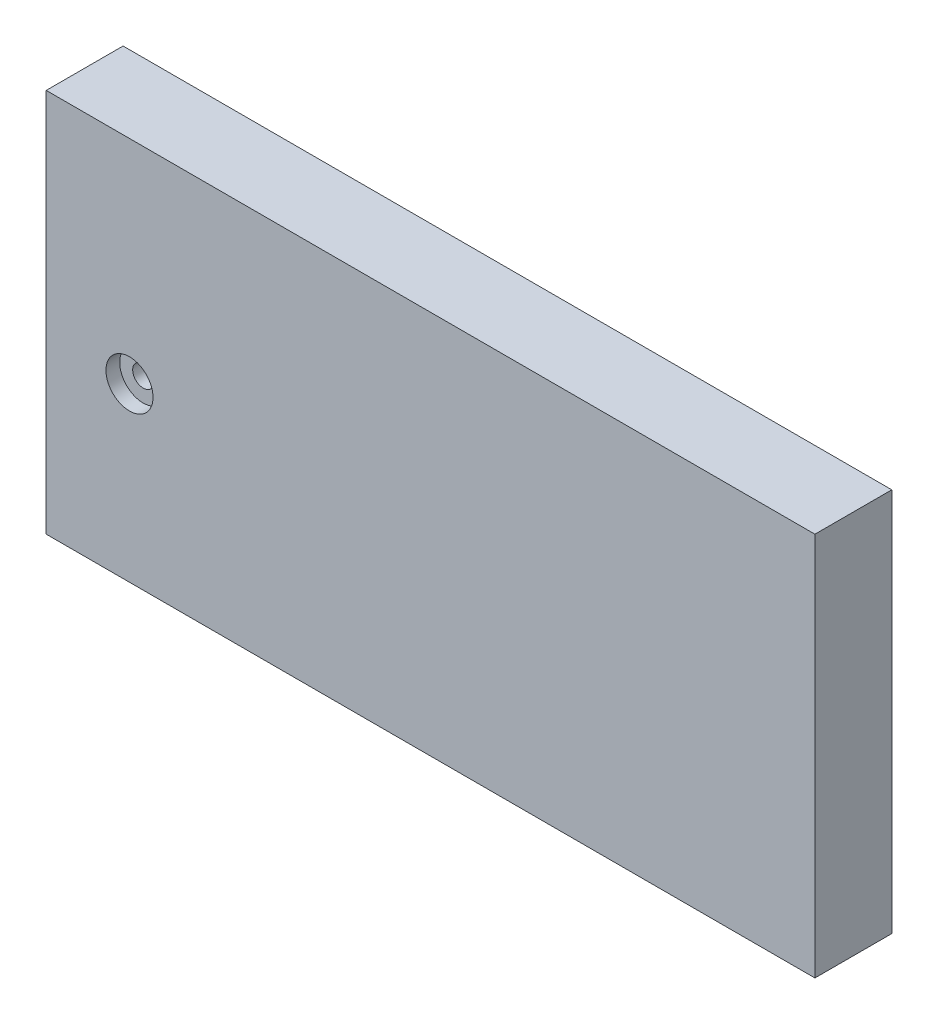
from build123d import *

# Parameters (mm, degrees)
SKETCH1_W                               = 200
SKETCH1_H                               = 100
BOSS_EXTRUDE1_DEPTH                     = 20
CBORE_FOR_M5_HEX_HEAD_BOLT1_D           = 5.5
CBORE_FOR_M5_HEX_HEAD_BOLT1_CBORE_D     = 12.24
CBORE_FOR_M5_HEX_HEAD_BOLT1_CBORE_DEPTH = 3.58


with BuildPart() as part:
    # Sketch1 → Boss-Extrude1 (new body)
    with BuildSketch(Plane.XY):
        with Locations((100, 50)):
            Rectangle(SKETCH1_W, SKETCH1_H)
    extrude(amount=BOSS_EXTRUDE1_DEPTH)

    # CBORE for M5 Hex Head Bolt1 (through all)
    with Locations(Plane.XY.offset(20)):
        with Locations((21.66285913, 44.704015598)):
            CounterBoreHole(CBORE_FOR_M5_HEX_HEAD_BOLT1_D / 2, CBORE_FOR_M5_HEX_HEAD_BOLT1_CBORE_D / 2, CBORE_FOR_M5_HEX_HEAD_BOLT1_CBORE_DEPTH)


solid = part.part
